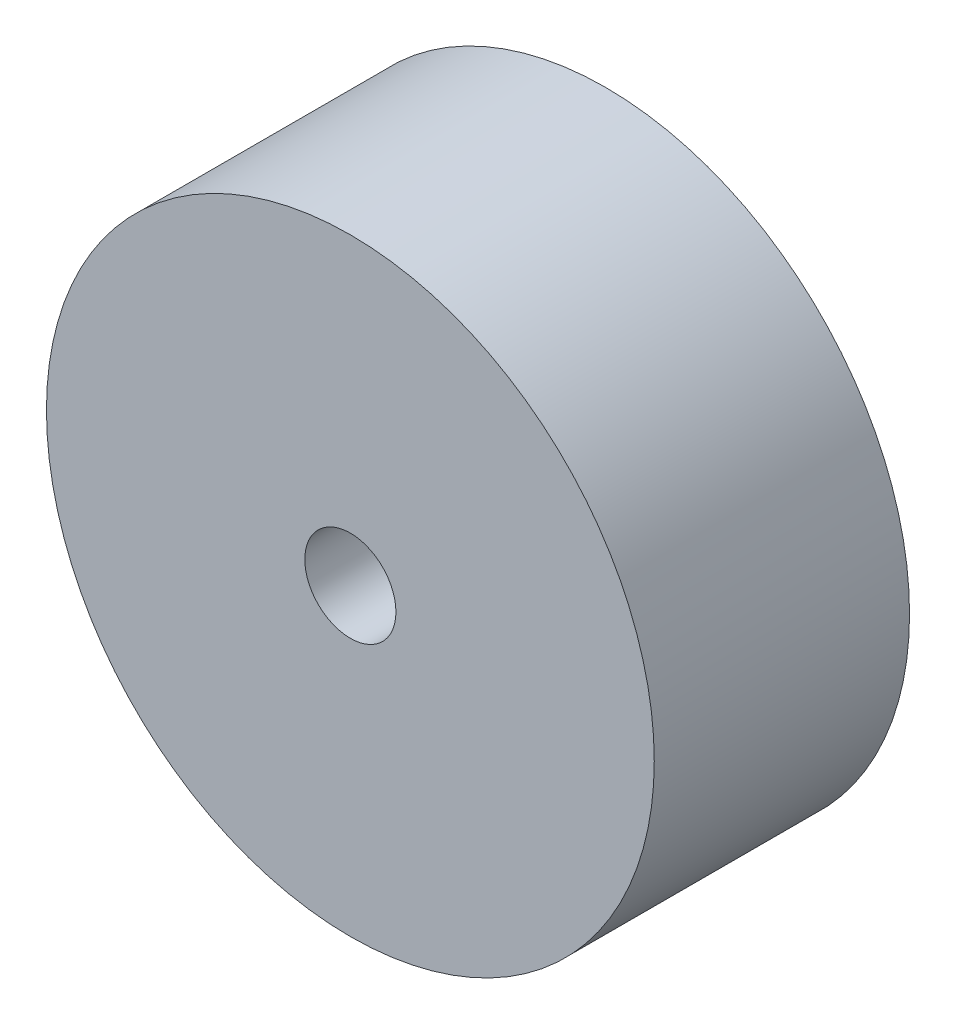
from build123d import *

# Parameters (mm, degrees)
ESBO_O1_R                = 50
RESSALTO_EXTRUS_O1_DEPTH = 42
ESBO_O2_R                = 7.5
CORTE_EXTRUS_O1_DEPTH    = 43


with BuildPart() as part:
    # Esboço1 → Ressalto-extrusão1 (new body)
    with BuildSketch(Plane.XY):
        Circle(ESBO_O1_R)
    extrude(amount=RESSALTO_EXTRUS_O1_DEPTH)

    # Esboço2 → Corte-extrusão1 (cut, through all)
    with BuildSketch(Plane.XY.offset(42)):
        Circle(ESBO_O2_R)
    extrude(amount=-CORTE_EXTRUS_O1_DEPTH, mode=Mode.SUBTRACT)


solid = part.part
